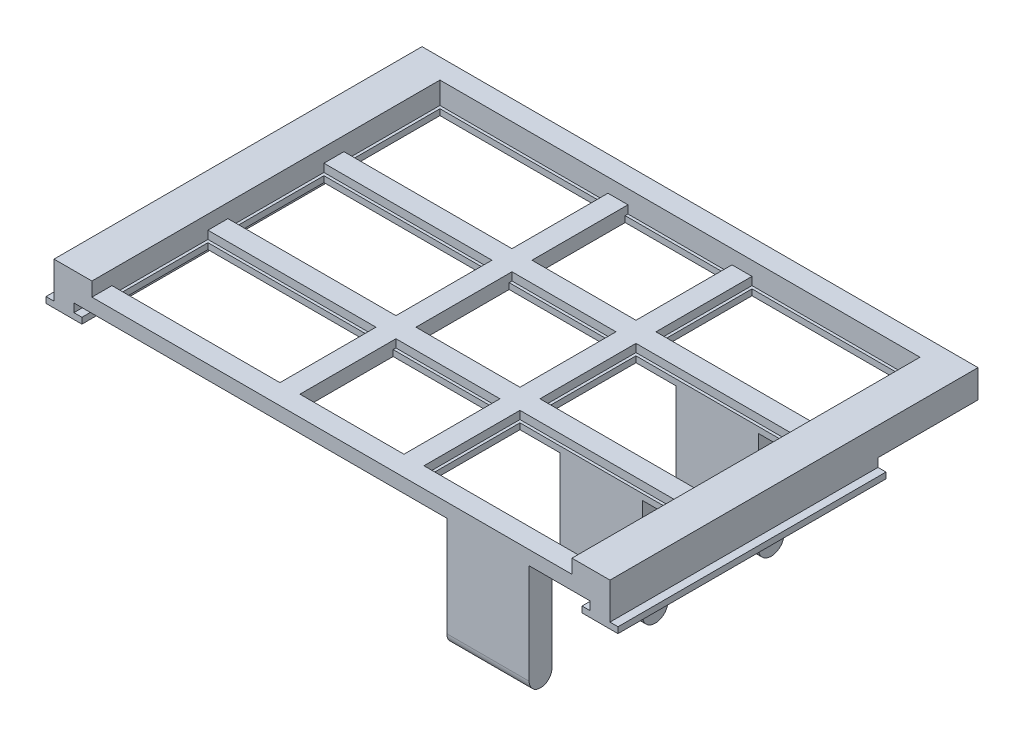
from build123d import *

# Parameters (mm, degrees)
SKETCH1_W            = 148
SKETCH1_H            = 130
SKETCH1_W_2          = 120
SKETCH1_H_2          = 110
BOSS_EXTRUDE2_DEPTH  = 10
SKETCH2_W            = 120
SKETCH2_H            = 24
SKETCH2_W_2          = 118.6
SKETCH2_H_2          = 22.6
SKETCH2_H_3          = 23
SKETCH2_H_4          = 21.6
SKETCH2_H_5          = 5
BOSS_EXTRUDE3_DEPTH  = 1.5
SKETCH3_W            = 120
SKETCH3_H            = 5
BOSS_EXTRUDE4_DEPTH  = 2
SKETCH4_W            = 5
SKETCH4_H            = 110
BOSS_EXTRUDE5_DEPTH  = 3.5
SKETCH5_W            = 5
SKETCH5_H            = 22.6
SKETCH5_H_2          = 21.6
CUT_EXTRUDE1_DEPTH   = 10
SKETCH6_W            = 5
SKETCH6_H            = 0.7
CUT_EXTRUDE2_DEPTH   = 2
SKETCH7_W            = 5
SKETCH7_H            = 24
BOSS_EXTRUDE7_DEPTH  = 3.5
SKETCH8_W            = 0.7
SKETCH8_H            = 22.6
BOSS_EXTRUDE8_DEPTH  = 1.5
SKETCH9_W            = 26
SKETCH9_H            = 0.7
CUT_EXTRUDE3_DEPTH   = 1.5
SKETCH10_W           = 0.7
SKETCH10_H           = 22.6
BOSS_EXTRUDE9_DEPTH  = 1.5
SKETCH11_W           = 5
SKETCH11_H           = 70
BOSS_EXTRUDE10_DEPTH = 3
SKETCH12_W           = 4.519389616
SKETCH12_H           = 130
SKETCH12_W_2         = 4.5
CUT_EXTRUDE4_DEPTH   = 20
SKETCH13_W           = 138.980610384
SKETCH13_H           = 30
SKETCH13_H_2         = 5
CUT_EXTRUDE5_DEPTH   = 20
SKETCH14_W           = 138.980610384
SKETCH14_H           = 3
CUT_EXTRUDE6_DEPTH   = 20
SKETCH15_W           = 4.980610384
SKETCH15_H           = 3
SKETCH15_W_2         = 5
CUT_EXTRUDE7_DEPTH   = 20
SKETCH16_W           = 138.980610384
SKETCH16_H           = 3
CUT_EXTRUDE8_DEPTH   = 200
SKETCH17_W           = 20.6
SKETCH17_H           = 6.4
SKETCH17_H_2         = 5.7
BOSS_EXTRUDE11_DEPTH = 10
BOSS_EXTRUDE12_DEPTH = 20.6
BOSS_EXTRUDE13_DEPTH = 20.6
SKETCH20_W           = 5
SKETCH20_H           = 67
SKETCH20_W_2         = 4.980610384
CUT_EXTRUDE9_DEPTH   = 0.9
SKETCH21_W           = 8.980610384
SKETCH21_H           = 67
BOSS_EXTRUDE14_DEPTH = 1.5


with BuildPart() as part:
    # Sketch1 → Boss-Extrude2 (new body)
    with BuildSketch(Plane(origin=(0, 0, 0), x_dir=(1, 0, 0), z_dir=(0, 1, 0))):
        with Locations((110.217300352, 48.854396258)):
            Rectangle(SKETCH1_W, SKETCH1_H)
        with Locations((110.217300352, 48.854396258)):
            Rectangle(SKETCH1_W_2, SKETCH1_H_2, mode=Mode.SUBTRACT)
    extrude(amount=BOSS_EXTRUDE2_DEPTH)

    # Sketch2 → Boss-Extrude3 (add)
    with BuildSketch(Plane.XZ):
        with Locations((110.217300352, -91.854396258)):
            Rectangle(SKETCH2_W, SKETCH2_H)
        with Locations((110.217300352, -91.854396258)):
            Rectangle(SKETCH2_W_2, SKETCH2_H_2, mode=Mode.SUBTRACT)
        with Locations((110.217300352, -62.854396258)):
            Rectangle(SKETCH2_W, SKETCH2_H)
        with Locations((110.217300352, -62.854396258)):
            Rectangle(SKETCH2_W_2, SKETCH2_H_2, mode=Mode.SUBTRACT)
        with Locations((110.217300352, -33.854396258)):
            Rectangle(SKETCH2_W, SKETCH2_H)
        with Locations((110.217300352, -33.854396258)):
            Rectangle(SKETCH2_W_2, SKETCH2_H_2, mode=Mode.SUBTRACT)
        with Locations((110.217300352, -5.354396258)):
            Rectangle(SKETCH2_W, SKETCH2_H_3)
        with Locations((110.217300352, -5.354396258)):
            Rectangle(SKETCH2_W_2, SKETCH2_H_4, mode=Mode.SUBTRACT)
        with Locations((110.217300352, -19.354396258)):
            Rectangle(SKETCH2_W, SKETCH2_H_5)
        with Locations((110.217300352, -48.354396258)):
            Rectangle(SKETCH2_W, SKETCH2_H_5)
        with Locations((110.217300352, -77.354396258)):
            Rectangle(SKETCH2_W, SKETCH2_H_5)
    extrude(amount=-BOSS_EXTRUDE3_DEPTH)

    # Sketch3 → Boss-Extrude4 (add)
    with BuildSketch(Plane(origin=(0, 1.5, 0), x_dir=(1, 0, 0), z_dir=(0, 1, 0))):
        with Locations((110.217300352, 77.354396258)):
            Rectangle(SKETCH3_W, SKETCH3_H)
        with Locations((110.217300352, 48.354396258)):
            Rectangle(SKETCH3_W, SKETCH3_H)
        with Locations((110.217300352, 19.354396258)):
            Rectangle(SKETCH3_W, SKETCH3_H)
    extrude(amount=BOSS_EXTRUDE4_DEPTH)

    # Sketch4 → Boss-Extrude5 (add)
    with BuildSketch(Plane(origin=(0, 0, 0), x_dir=(-1, 0, 0), z_dir=(0, -1, 0))):
        with Locations((-89.717300352, 48.854396258)):
            Rectangle(SKETCH4_W, SKETCH4_H)
        with Locations((-125.717300352, 48.854396258)):
            Rectangle(SKETCH4_W, SKETCH4_H)
    extrude(amount=-BOSS_EXTRUDE5_DEPTH)

    # Sketch5 → Cut-Extrude1 (cut)
    with BuildSketch(Plane(origin=(0, 0, 0), x_dir=(-1, 0, 0), z_dir=(0, -1, 0))):
        with Locations((-89.717300352, 91.854396258)):
            Rectangle(SKETCH5_W, SKETCH5_H)
        with Locations((-89.717300352, 5.354396258)):
            Rectangle(SKETCH5_W, SKETCH5_H_2)
        with Locations((-89.717300352, 33.854396258)):
            Rectangle(SKETCH5_W, SKETCH5_H)
        with Locations((-89.717300352, 62.854396258)):
            Rectangle(SKETCH5_W, SKETCH5_H)
    extrude(amount=-CUT_EXTRUDE1_DEPTH, mode=Mode.SUBTRACT)

    # Sketch6 → Cut-Extrude2 (cut)
    with BuildSketch(Plane(origin=(0, 1.5, 0), x_dir=(1, 0, 0), z_dir=(0, 1, 0))):
        with Locations((89.717300352, 103.504396258)):
            Rectangle(SKETCH6_W, SKETCH6_H)
        with Locations((89.717300352, 80.204396258)):
            Rectangle(SKETCH6_W, SKETCH6_H)
        with Locations((89.717300352, 74.504396258)):
            Rectangle(SKETCH6_W, SKETCH6_H)
        with Locations((89.717300352, 51.204396258)):
            Rectangle(SKETCH6_W, SKETCH6_H)
        with Locations((89.717300352, 45.504396258)):
            Rectangle(SKETCH6_W, SKETCH6_H)
        with Locations((89.717300352, 22.204396258)):
            Rectangle(SKETCH6_W, SKETCH6_H)
        with Locations((89.717300352, 16.504396258)):
            Rectangle(SKETCH6_W, SKETCH6_H)
        with Locations((89.717300352, -5.795603742)):
            Rectangle(SKETCH6_W, SKETCH6_H)
    extrude(amount=CUT_EXTRUDE2_DEPTH, mode=Mode.SUBTRACT)

    # Sketch7 → Boss-Extrude7 (add)
    with BuildSketch(Plane(origin=(0, 0, 0), x_dir=(-1, 0, 0), z_dir=(0, -1, 0))):
        with Locations((-94.717300352, 91.854396258)):
            Rectangle(SKETCH7_W, SKETCH7_H)
        with Locations((-94.717300352, 62.854396258)):
            Rectangle(SKETCH7_W, SKETCH7_H)
        Polygon((-97.217300352, 16.854396258), (-97.217300352, -6.145603742), (-92.217300352, -6.170565448), (-92.217300352, 16.854396258), align=None)
        with Locations((-94.717300352, 33.854396258)):
            Rectangle(SKETCH7_W, SKETCH7_H)
    extrude(amount=-BOSS_EXTRUDE7_DEPTH)

    # Sketch8 → Boss-Extrude8 (add)
    with BuildSketch(Plane(origin=(0, 0, 0), x_dir=(-1, 0, 0), z_dir=(0, -1, 0))):
        with Locations((-91.867300352, 91.854396258)):
            Rectangle(SKETCH8_W, SKETCH8_H)
        with Locations((-91.867300352, 62.854396258)):
            Rectangle(SKETCH8_W, SKETCH8_H)
        with Locations((-91.867300352, 33.854396258)):
            Rectangle(SKETCH8_W, SKETCH8_H)
    extrude(amount=-BOSS_EXTRUDE8_DEPTH)

    # Sketch9 → Cut-Extrude3 (cut)
    with BuildSketch(Plane(origin=(0, 0, 0), x_dir=(-1, 0, 0), z_dir=(0, -1, 0))):
        Polygon((-50.217300352, 16.854396258), (-92.217300352, 16.854396258), (-92.217300352, 16.154396258), (-50.917300352, 16.154396258), (-50.917300352, -5.445603742), (-92.217300352, -5.445603742), (-92.217300352, -6.145603742), (-50.217300352, -6.145603742), align=None)
        Polygon((-170.217300352, -6.145603742), (-128.217300352, -6.145603742), (-128.217300352, -5.445603742), (-169.517300352, -5.445603742), (-169.517300352, 16.154396258), (-128.217300352, 16.154396258), (-128.217300352, 16.854396258), (-170.217300352, 16.854396258), align=None)
        with Locations((-110.217300352, 16.504396258)):
            Rectangle(SKETCH9_W, SKETCH9_H)
        with Locations((-110.217300352, -5.795603742)):
            Rectangle(SKETCH9_W, SKETCH9_H)
    extrude(amount=-CUT_EXTRUDE3_DEPTH, mode=Mode.SUBTRACT)

    # Sketch10 → Boss-Extrude9 (add)
    with BuildSketch(Plane(origin=(0, 0, 0), x_dir=(-1, 0, 0), z_dir=(0, -1, 0))):
        with Locations((-128.567300352, 91.854396258)):
            Rectangle(SKETCH10_W, SKETCH10_H)
        with Locations((-128.567300352, 62.854396258)):
            Rectangle(SKETCH10_W, SKETCH10_H)
        with Locations((-128.567300352, 33.854396258)):
            Rectangle(SKETCH10_W, SKETCH10_H)
    extrude(amount=-BOSS_EXTRUDE9_DEPTH)

    # Sketch11 → Boss-Extrude10 (add)
    with BuildSketch(Plane(origin=(0, 0, 0), x_dir=(-1, 0, 0), z_dir=(0, -1, 0))):
        with Locations((-43.217300352, 48.854396258)):
            Rectangle(SKETCH11_W, SKETCH11_H)
        with Locations((-177.217300352, 48.854396258)):
            Rectangle(SKETCH11_W, SKETCH11_H)
    extrude(amount=BOSS_EXTRUDE10_DEPTH)

    # Sketch12 → Cut-Extrude4 (cut)
    with BuildSketch(Plane(origin=(0, 10, 0), x_dir=(1, 0, 0), z_dir=(0, 1, 0))):
        with Locations((38.47699516, 48.854396258)):
            Rectangle(SKETCH12_W, SKETCH12_H)
        with Locations((181.967300352, 48.854396258)):
            Rectangle(SKETCH12_W_2, SKETCH12_H)
    extrude(amount=-CUT_EXTRUDE4_DEPTH, mode=Mode.SUBTRACT)

    # Sketch13 → Cut-Extrude5 (cut)
    with BuildSketch(Plane(origin=(0, 0, 0), x_dir=(-1, 0, 0), z_dir=(0, -1, 0))):
        with Locations((-110.22699516, -1.145603742)):
            Rectangle(SKETCH13_W, SKETCH13_H)
        with Locations((-110.22699516, 111.354396258)):
            Rectangle(SKETCH13_W, SKETCH13_H_2)
    extrude(amount=-CUT_EXTRUDE5_DEPTH, mode=Mode.SUBTRACT)

    # Sketch14 → Cut-Extrude6 (cut)
    with BuildSketch(Plane(origin=(0, 0, 0), x_dir=(-1, 0, 0), z_dir=(0, -1, 0))):
        with Locations((-110.22699516, 15.354396258)):
            Rectangle(SKETCH14_W, SKETCH14_H)
    extrude(amount=-CUT_EXTRUDE6_DEPTH, mode=Mode.SUBTRACT)

    # Sketch15 → Cut-Extrude7 (cut)
    with BuildSketch(Plane(origin=(0, -3, 0), x_dir=(-1, 0, 0), z_dir=(0, -1, 0))):
        with Locations((-43.22699516, 15.354396258)):
            Rectangle(SKETCH15_W, SKETCH15_H)
        with Locations((-177.217300352, 15.354396258)):
            Rectangle(SKETCH15_W_2, SKETCH15_H)
    extrude(amount=-CUT_EXTRUDE7_DEPTH, mode=Mode.SUBTRACT)

    # Sketch16 → Cut-Extrude8 (cut)
    with BuildSketch(Plane.XY.offset(-16.854396258)):
        with Locations((110.22699516, 8.5)):
            Rectangle(SKETCH16_W, SKETCH16_H)
    extrude(amount=-CUT_EXTRUDE8_DEPTH, mode=Mode.SUBTRACT)

    # Sketch17 → Boss-Extrude11 (add)
    with BuildSketch(Plane(origin=(0, 0, 0), x_dir=(-1, 0, 0), z_dir=(0, -1, 0))):
        with Locations((-149.217300352, 77.354396258)):
            Rectangle(SKETCH17_W, SKETCH17_H)
        with Locations((-149.217300352, 48.354396258)):
            Rectangle(SKETCH17_W, SKETCH17_H)
        with Locations((-149.217300352, 19.704396258)):
            Rectangle(SKETCH17_W, SKETCH17_H_2)
    extrude(amount=BOSS_EXTRUDE11_DEPTH)

    # Sketch18 → Boss-Extrude12 (add)
    with BuildSketch(Plane.ZY.offset(-138.917300352)):
        with BuildLine():
            Line((-22.554396258, -10), (-16.854396258, -10))
            ThreePointArc((-16.854396258, -10), (-19.704396258, -12.85), (-22.554396258, -10))
        make_face()
        with BuildLine():
            Line((-45.154396258, -10), (-51.554396258, -10))
            ThreePointArc((-51.554396258, -10), (-48.354396258, -13.2), (-45.154396258, -10))
        make_face()
        with BuildLine():
            Line((-74.154396258, -10), (-80.554396258, -10))
            ThreePointArc((-80.554396258, -10), (-77.354396258, -13.2), (-74.154396258, -10))
        make_face()
    extrude(amount=-BOSS_EXTRUDE12_DEPTH)

    # Sketch19 → Boss-Extrude13 (add)
    with BuildSketch(Plane.ZY.offset(-138.917300352)):
        with BuildLine():
            Line((-16.854396258, -10), (-16.854396258, -25))
            ThreePointArc((-16.854396258, -25), (-19.704396258, -27.85), (-22.554396258, -25))
            Line((-22.554396258, -25), (-22.554396258, -10))
            ThreePointArc((-22.554396258, -10), (-19.704396258, -12.85), (-16.854396258, -10))
        make_face()
        with BuildLine():
            Line((-45.154396258, -10), (-45.154396258, -25))
            ThreePointArc((-45.154396258, -25), (-48.354396258, -28.2), (-51.554396258, -25))
            Line((-51.554396258, -25), (-51.554396258, -10))
            Line((-51.554396258, -10), (-45.154396258, -10))
        make_face()
        with BuildLine():
            Line((-74.154396258, -10), (-74.154396258, -25))
            ThreePointArc((-74.154396258, -25), (-77.354396258, -28.2), (-80.554396258, -25))
            Line((-80.554396258, -25), (-80.554396258, -10))
            Line((-80.554396258, -10), (-74.154396258, -10))
        make_face()
    extrude(amount=-BOSS_EXTRUDE13_DEPTH)

    # Sketch20 → Cut-Extrude9 (cut)
    with BuildSketch(Plane(origin=(0, -3, 0), x_dir=(-1, 0, 0), z_dir=(0, -1, 0))):
        with Locations((-177.217300352, 50.354396258)):
            Rectangle(SKETCH20_W, SKETCH20_H)
        with Locations((-43.22699516, 50.354396258)):
            Rectangle(SKETCH20_W_2, SKETCH20_H)
    extrude(amount=-CUT_EXTRUDE9_DEPTH, mode=Mode.SUBTRACT)

    # Sketch21 → Boss-Extrude14 (add)
    with BuildSketch(Plane(origin=(0, -2.1, 0), x_dir=(-1, 0, 0), z_dir=(0, -1, 0))):
        with Locations((-43.22699516, 50.354396258)):
            Rectangle(SKETCH21_W, SKETCH21_H)
        with Locations((-177.22699516, 50.354396258)):
            Rectangle(SKETCH21_W, SKETCH21_H)
    extrude(amount=BOSS_EXTRUDE14_DEPTH)


solid = part.part
